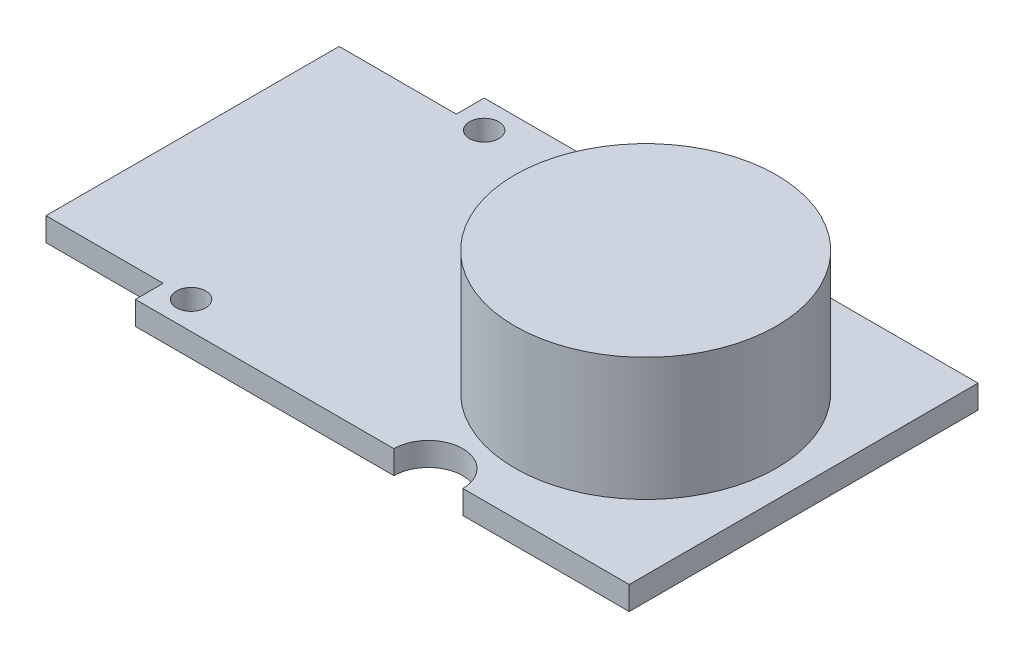
from build123d import *

# Parameters (mm, degrees)
SKETCH1_R               = 1
BOSS_EXTRUDE1_DEPTH     = 1.6
SKETCH2_R               = 8.931361996
BOSS_EXTRUDE2_DEPTH     = 8.4
SKETCH3_W               = 8
SKETCH3_H               = 1.9
CUT_EXTRUDE1_DEPTH      = 9.4
CUT_EXTRUDE1_DEPTH_BACK = 2.6


with BuildPart() as part:
    # Sketch1 → Boss-Extrude1 (new body)
    with BuildSketch(Plane(origin=(0, 0, 0), x_dir=(1, 0, 0), z_dir=(0, 1, 0))):
        with BuildLine():
            Line((10.779760555, 11.9), (-0.580107175, 11.9))
            ThreePointArc((-0.580107175, 11.9), (-2.930107175, 9.55), (-5.280107175, 11.9))
            Line((-5.280107175, 11.9), (-30.920239445, 11.9))
            Line((-30.920239445, 11.9), (-30.920239445, -11.9))
            Line((-30.920239445, -11.9), (-5.280107175, -11.9))
            ThreePointArc((-5.280107175, -11.9), (-2.930107175, -9.55), (-0.580107175, -11.9))
            Line((-0.580107175, -11.9), (10.779760555, -11.9))
            Line((10.779760555, -11.9), (10.779760555, 11.9))
        make_face()
        with Locations((-21.020239445, -10)):
            Circle(SKETCH1_R, mode=Mode.SUBTRACT)
        with Locations((-21.020239445, 10)):
            Circle(SKETCH1_R, mode=Mode.SUBTRACT)
    extrude(amount=BOSS_EXTRUDE1_DEPTH)

    # Sketch2 → Boss-Extrude2 (add)
    with BuildSketch(Plane(origin=(0, 1.6, 0), x_dir=(1, 0, 0), z_dir=(0, 1, 0))):
        Circle(SKETCH2_R)
    extrude(amount=BOSS_EXTRUDE2_DEPTH)

    # Sketch3 → Cut-Extrude1 (cut, two sides)
    with BuildSketch(Plane(origin=(0, 1.6, 0), x_dir=(1, 0, 0), z_dir=(0, 1, 0))) as cut_extrude1_sk:
        with Locations((-26.920239445, 10.95)):
            Rectangle(SKETCH3_W, SKETCH3_H)
        with Locations((-26.920239445, -10.95)):
            Rectangle(SKETCH3_W, SKETCH3_H)
    extrude(amount=CUT_EXTRUDE1_DEPTH, mode=Mode.SUBTRACT)
    extrude(cut_extrude1_sk.sketch, amount=-CUT_EXTRUDE1_DEPTH_BACK, mode=Mode.SUBTRACT)


solid = part.part
